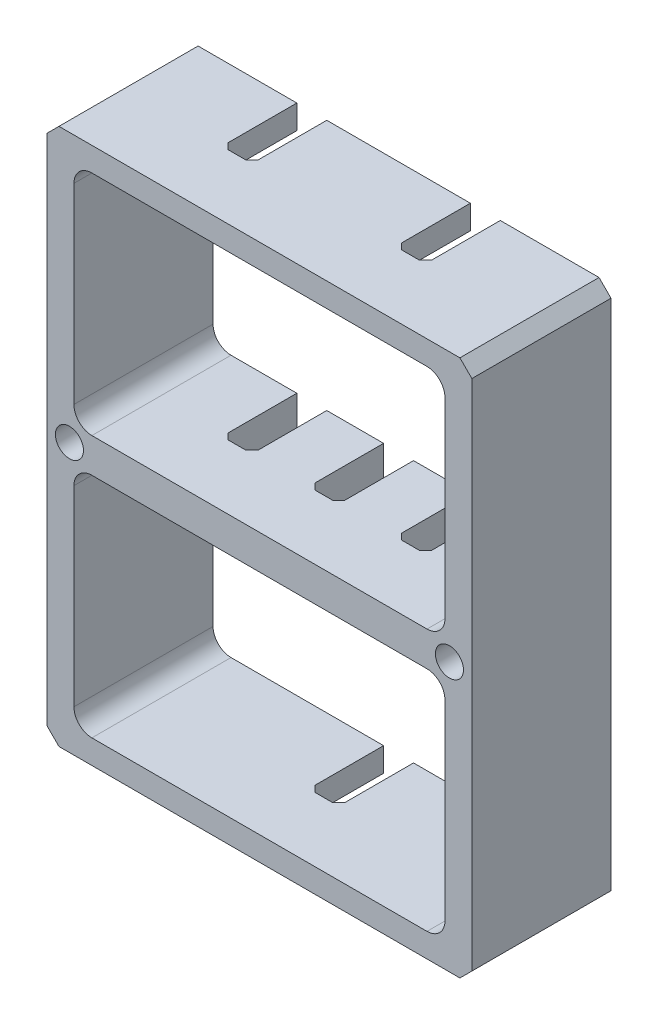
from build123d import *

# Parameters (mm, degrees)
SKETCH1_W               = 18.034
SKETCH1_H               = 22.7965
SKETCH1_W_2             = 15.748
SKETCH1_H_2             = 9.652
BOSS_EXTRUDE1_DEPTH     = 5.9055
SKETCH2_W               = 1.27
SKETCH2_H               = 1.016
SKETCH2_H_2             = 1.4605
CUT_EXTRUDE_THIN2_DEPTH = 3.175
CHAMFER1_SIZE           = 0.254
CHAMFER2_SIZE           = 0.508
FILLET1_R               = 0.762
F_0_80_TAPPED_HOLE1_D   = 1.19126


with BuildPart() as part:
    # Sketch1 → Boss-Extrude1 (new body)
    with BuildSketch(Plane.XY):
        with Locations((22.86, -68.54825)):
            Rectangle(SKETCH1_W, SKETCH1_H)
        with Locations((22.86, -62.992)):
            Rectangle(SKETCH1_W_2, SKETCH1_H_2, mode=Mode.SUBTRACT)
        with Locations((22.86, -74.1045)):
            Rectangle(SKETCH1_W_2, SKETCH1_H_2, mode=Mode.SUBTRACT)
    extrude(amount=BOSS_EXTRUDE1_DEPTH)

    # Sketch2 → Cut-Extrude-Thin2 (cut)
    with BuildSketch(Plane(origin=(0, 0, 0), x_dir=(-1, 0, 0), z_dir=(0, 0, -1))):
        with Locations((-22.86, -79.4385)):
            Rectangle(SKETCH2_W, SKETCH2_H)
        with Locations((-19.177, -57.658)):
            Rectangle(SKETCH2_W, SKETCH2_H)
        with Locations((-26.543, -57.658)):
            Rectangle(SKETCH2_W, SKETCH2_H)
        with Locations((-22.86, -68.54825)):
            Rectangle(SKETCH2_W, SKETCH2_H_2)
        with Locations((-19.177, -68.54825)):
            Rectangle(SKETCH2_W, SKETCH2_H_2)
        with Locations((-26.543, -68.54825)):
            Rectangle(SKETCH2_W, SKETCH2_H_2)
    extrude(amount=-CUT_EXTRUDE_THIN2_DEPTH, mode=Mode.SUBTRACT)

    # Chamfer1
    chamfer1_edges = [part.edges().sort_by_distance(p)[0] for p in [
        (22.225, -68.54825, 3.175),
        (23.495, -68.54825, 3.175),
        (25.908, -68.54825, 3.175),
        (27.178, -68.54825, 3.175),
        (23.495, -79.4385, 3.175),
        (22.225, -79.4385, 3.175),
        (19.812, -57.658, 3.175),
        (18.542, -57.658, 3.175),
        (27.178, -57.658, 3.175),
        (25.908, -57.658, 3.175),
        (18.542, -68.54825, 3.175),
        (19.812, -68.54825, 3.175),
    ]]
    chamfer(chamfer1_edges, length=CHAMFER1_SIZE)

    # Chamfer2
    chamfer2_edges = [part.edges().sort_by_distance(p)[0] for p in [
        (31.877, -57.15, 2.95275),
        (31.877, -79.9465, 2.95275),
        (13.843, -79.9465, 2.95275),
        (13.843, -57.15, 2.95275),
    ]]
    chamfer(chamfer2_edges, length=CHAMFER2_SIZE)

    # Fillet1
    fillet1_edges = [part.edges().sort_by_distance(p)[0] for p in [
        (30.734, -67.818, 2.95275),
        (30.734, -58.166, 2.95275),
        (14.986, -78.9305, 2.95275),
        (30.734, -78.9305, 2.95275),
        (14.986, -58.166, 2.95275),
        (14.986, -67.818, 2.95275),
        (30.734, -69.2785, 2.95275),
        (14.986, -69.2785, 2.95275),
    ]]
    fillet(fillet1_edges, radius=FILLET1_R)

    # #0-80 Tapped Hole1 (through all)
    with Locations(Plane(origin=(0, 0, 0), x_dir=(-1, 0, 0), z_dir=(0, 0, -1))):
        with Locations((-14.7955, -68.54825), (-30.9245, -68.54825)):
            Hole(F_0_80_TAPPED_HOLE1_D / 2)


solid = part.part
